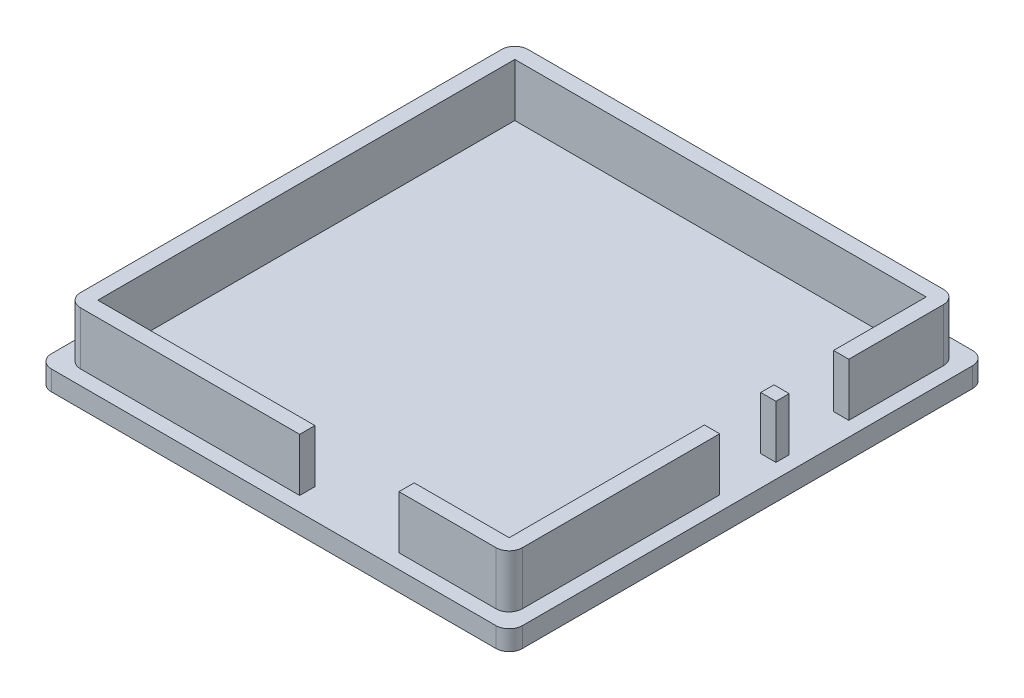
from build123d import *

# Parameters (mm, degrees)
ESBO_O1_W                = 71.15
ESBO_O1_H                = 72
RESSALTO_EXTRUS_O1_DEPTH = 1.5
ESBO_O2_W                = 66.75
ESBO_O2_H                = 67.6
ESBO_O2_W_2              = 62.15
ESBO_O2_H_2              = 63
RESSALTO_EXTRUS_O2_DEPTH = 8
FILETE1_R                = 2
ESBO_O3_W                = 9
ESBO_O3_H                = 8
CORTE_EXTRUS_O1_DEPTH    = 4.5
ESBO_O4_W                = 8.5
ESBO_O4_H                = 8
CORTE_EXTRUS_O2_DEPTH    = 4.5
ESBO_O5_W                = 15
ESBO_O5_H                = 8
CORTE_EXTRUS_O3_DEPTH    = 4.5


with BuildPart() as part:
    # Esboço1 → Ressalto-extrusão1 (new body, symmetric)
    with BuildSketch(Plane(origin=(0, 0, 0), x_dir=(1, 0, 0), z_dir=(0, 1, 0))):
        Rectangle(ESBO_O1_W, ESBO_O1_H)
    extrude(amount=RESSALTO_EXTRUS_O1_DEPTH, both=True)

    # Esboço2 → Ressalto-extrusão2 (add)
    with BuildSketch(Plane(origin=(0, 1.5, 0), x_dir=(1, 0, 0), z_dir=(0, 1, 0))):
        Rectangle(ESBO_O2_W, ESBO_O2_H)
        Rectangle(ESBO_O2_W_2, ESBO_O2_H_2, mode=Mode.SUBTRACT)
    extrude(amount=RESSALTO_EXTRUS_O2_DEPTH)

    # Filete1
    filete1_edges = [part.edges().sort_by_distance(p)[0] for p in [
        (-33.375, 5.5, 33.8),
        (33.375, 5.5, 33.8),
        (33.375, 5.5, -33.8),
        (-33.375, 5.5, -33.8),
        (35.575, 0, 36),
        (-35.575, 0, 36),
        (-35.575, 0, -36),
        (35.575, 0, -36),
    ]]
    fillet(filete1_edges, radius=FILETE1_R)

    # Esboço3 → Corte-extrusão1 (cut)
    with BuildSketch(Plane.ZY.offset(-31.075)):
        with Locations((-13, 5.5)):
            Rectangle(ESBO_O3_W, ESBO_O3_H)
    extrude(amount=-CORTE_EXTRUS_O1_DEPTH, mode=Mode.SUBTRACT)

    # Esboço4 → Corte-extrusão2 (cut)
    with BuildSketch(Plane.ZY.offset(-31.075)):
        with Locations((-2.25, 5.5)):
            Rectangle(ESBO_O4_W, ESBO_O4_H)
    extrude(amount=-CORTE_EXTRUS_O2_DEPTH, mode=Mode.SUBTRACT)

    # Esboço5 → Corte-extrusão3 (cut)
    with BuildSketch(Plane(origin=(0, 0, 31.5), x_dir=(-1, 0, 0), z_dir=(0, 0, -1))):
        with Locations((-9.225, 5.5)):
            Rectangle(ESBO_O5_W, ESBO_O5_H)
    extrude(amount=-CORTE_EXTRUS_O3_DEPTH, mode=Mode.SUBTRACT)


solid = part.part
